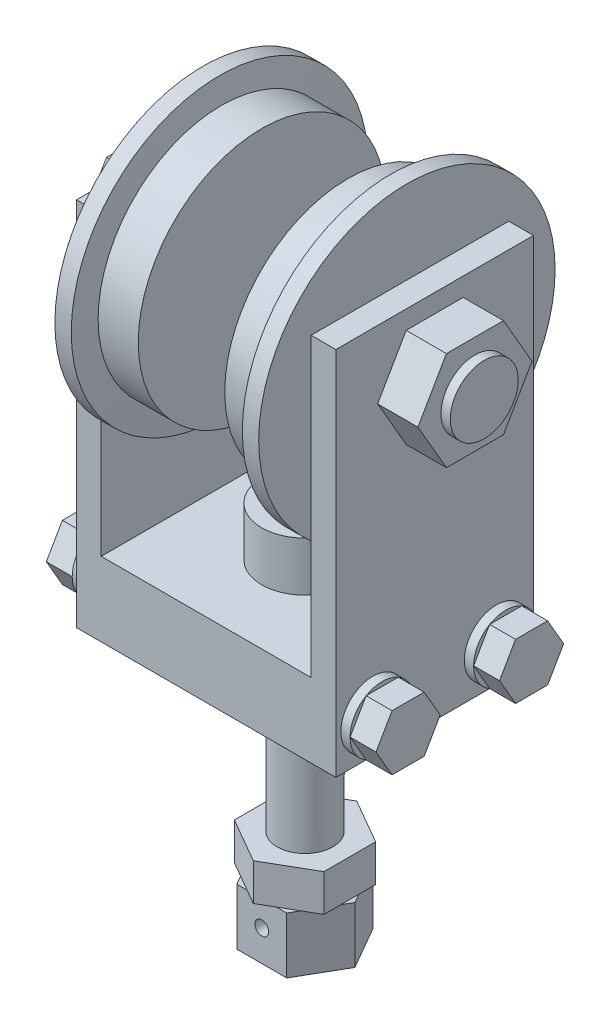
from build123d import *

# Parameters (mm, degrees)
YOKE_CROSS_SECTION_W           = 101.6
YOKE_CROSS_SECTION_H           = 38.1
YOKE_DEPTH                     = 53.975
SIDEPLATE_PROFILE_W            = 101.6
SIDEPLATE_PROFILE_H            = 190.5
SIDEPLATE_DEPTH                = 12.7
WHEEL_PIN_NUT_DEPTH            = 20.701
WHEEL_PIN_PROJECTION_PROFILE_R = 17.4625
WHEEL_PIN_PROJECTION_DEPTH     = 4.7625
LOCKNUTS_PROFILE_R             = 16.4973
LOCKNUTS_DEPTH                 = 4.7625
SCREWS_DEPTH                   = 13.3096
PROFILE_R                      = 22.225
KING_BOLT_HEAD_DEPTH           = 25.4
DIA_R                          = 14.2875
KING_BOLT_DEPTH                = 82.55
KING_BOLT_JAM_NUT_DEPTH        = 19.05
KING_BOLT_NUT_DEPTH            = 28.9306
SKETCH5_R                      = 14.2875
EXTENDED_KING_BOLT_DEPTH       = 6.35
CHAMFER1_SIZE                  = 2.38125
COTTER_PIN_HOLE_REACH          = 100.425
SKETCH7_R                      = 3.571875
SKETCH8_R                      = 30.1625
SKETCH8_R_2                    = 25.4
SPACER_DEPTH                   = 12.7


with BuildPart() as part:
    # YOKE CROSS SECTION → YOKE (new body)
    with BuildSketch(Plane(origin=(0, 0, 0), x_dir=(0, 0, -1), z_dir=(1, 0, 0))):
        with Locations((0, 19.05)):
            Rectangle(YOKE_CROSS_SECTION_W, YOKE_CROSS_SECTION_H)
    extrude(amount=YOKE_DEPTH)

    # SIDEPLATE PROFILE → SIDEPLATE (add)
    with BuildSketch(Plane(origin=(53.975, 0, 0), x_dir=(0, 0, -1), z_dir=(1, 0, 0))):
        with Locations((0, 95.25)):
            Rectangle(SIDEPLATE_PROFILE_W, SIDEPLATE_PROFILE_H)
    extrude(amount=SIDEPLATE_DEPTH)

    # WHEEL PIN NUT PROFILE → WHEEL PIN NUT (add)
    with BuildSketch(Plane(origin=(66.675, 0, 0), x_dir=(0, 0, -1), z_dir=(1, 0, 0))):
        Polygon((29.329393675, 155.575), (14.664696837, 180.975), (-14.664696837, 180.975), (-29.329393675, 155.575), (-14.664696837, 130.175), (14.664696837, 130.175), align=None)
    extrude(amount=WHEEL_PIN_NUT_DEPTH)

    # WHEEL PIN PROJECTION PROFILE → WHEEL PIN PROJECTION (add)
    with BuildSketch(Plane(origin=(87.376, 0, 0), x_dir=(0, 0, -1), z_dir=(1, 0, 0))):
        with Locations((0, 155.575)):
            Circle(WHEEL_PIN_PROJECTION_PROFILE_R)
    extrude(amount=WHEEL_PIN_PROJECTION_DEPTH)

    # LOCKNUTS PROFILE → LOCKNUTS (add)
    with BuildSketch(Plane(origin=(66.675, 0, 0), x_dir=(0, 0, -1), z_dir=(1, 0, 0))):
        with Locations((-31.75, 19.05)):
            Circle(LOCKNUTS_PROFILE_R)
    locknuts = extrude(amount=LOCKNUTS_DEPTH)

    # SCREWS PROFILE → SCREWS (add)
    with BuildSketch(Plane(origin=(71.4375, 0, 0), x_dir=(0, 0, -1), z_dir=(1, 0, 0))):
        Polygon((-15.252216058, 19.05), (-23.501108029, 33.3375), (-39.998891971, 33.3375), (-48.247783942, 19.05), (-39.998891971, 4.7625), (-23.501108029, 4.7625), align=None)
    screws = extrude(amount=SCREWS_DEPTH)

    # PROFILE → KING BOLT HEAD (add)
    with BuildSketch(Plane(origin=(0, 38.1, 0), x_dir=(-1, 0, 0), z_dir=(0, 1, 0))):
        with Locations(Location((0, 0, 0), (0, 0, 90))):  # turned: the seam where the file's is
            Circle(PROFILE_R)
    extrude(amount=KING_BOLT_HEAD_DEPTH)

    # Mirror1: LOCKNUTS, SCREWS across plane
    add(locknuts.mirror(Plane.XY))
    add(screws.mirror(Plane.XY))

    # Mirror5: part across plane


with BuildPart() as part_1:
    add(part.part)
    add(part.part.mirror(Plane(origin=(0, 0, 0), x_dir=(0, 0, 1), z_dir=(1, 0, 0))))

    # DIA. → KING BOLT (add)
    with BuildSketch(Plane.XZ):
        with Locations(Location((0, 0, 0), (0, 0, 90))):  # turned: the seam where the file's is
            Circle(DIA_R)
    extrude(amount=KING_BOLT_DEPTH)

    # KING BOLT JAN NUT PROFILE → KING BOLT JAM NUT (add)
    with BuildSketch(Plane.XZ.offset(82.55)):
        Polygon((0, -26.579763018), (23.01875, -13.289881509), (23.01875, 13.289881509), (0, 26.579763018), (-23.01875, 13.289881509), (-23.01875, -13.289881509), align=None)
    extrude(amount=KING_BOLT_JAM_NUT_DEPTH)

    # KING BOLT NUT PROFILE → KING BOLT NUT (add)
    with BuildSketch(Plane.XZ.offset(101.6)):
        Polygon((25.663219465, 0), (12.831609733, 22.225), (-12.831609733, 22.225), (-25.663219465, 0), (-12.831609733, -22.225), (12.831609733, -22.225), align=None)
    extrude(amount=KING_BOLT_NUT_DEPTH)

    # Sketch5 → EXTENDED KING BOLT (add)
    with BuildSketch(Plane.XZ.offset(130.5306)):
        with Locations(Location((0, 0, 0), (0, 0, 90))):  # turned: the seam where the file's is
            Circle(SKETCH5_R)
    extrude(amount=EXTENDED_KING_BOLT_DEPTH)

    # Chamfer1
    chamfer1_edges = [part_1.edges().sort_by_distance(p)[0] for p in [
        (0, -136.8806, -14.2875),
    ]]
    chamfer(chamfer1_edges, length=CHAMFER1_SIZE)

    # Sketch6 → WHEEL (revolve)
    with BuildSketch(Plane.XY, mode=Mode.PRIVATE) as wheel_sk:
        Polygon((52.3875, 180.975), (52.3875, 231.775), (43.973606027, 231.775), (42.8625, 219.075), (22.225, 219.075), (22.225, 155.575), (53.975, 155.575), (53.975, 180.975), align=None)
    wheel = revolve(wheel_sk.sketch.rotate(Axis((92.1385, 155.575, 0), (-1, 0, 0)), 90), axis=Axis((92.1385, 155.575, 0), (-1, 0, 0)))  # turned: the seam where the file's is

    # Mirror6: WHEEL across plane
    add(wheel.mirror(Plane(origin=(0, 0, 0), x_dir=(0, 0, 1), z_dir=(1, 0, 0))))

    # Sketch7 → COTTER PIN HOLE (cut, up to next)
    with BuildSketch(Plane.XY.offset(22.225), mode=Mode.PRIVATE) as cotter_pin_hole_sk1:
        with Locations((0, -114.6556)):
            Circle(SKETCH7_R)
    cotter_pin_hole_tool1 = extrude(cotter_pin_hole_sk1.sketch, amount=-COTTER_PIN_HOLE_REACH, mode=Mode.PRIVATE) & part_1.part
    add(cotter_pin_hole_tool1.solids().sort_by_distance((0, -114.6556, 22.225))[0], mode=Mode.SUBTRACT)

    # Sketch8 → SPACER (add)
    with BuildSketch(Plane.XZ):
        with Locations(Location((0, 0, 0), (0, 0, 90))):  # turned: the seam where the file's is
            Circle(SKETCH8_R)
        with Locations(Location((0, 0, 0), (0, 0, 270))):  # turned: the seam where the file's is
            Circle(SKETCH8_R_2, mode=Mode.SUBTRACT)
    extrude(amount=SPACER_DEPTH)


solid = part_1.part
